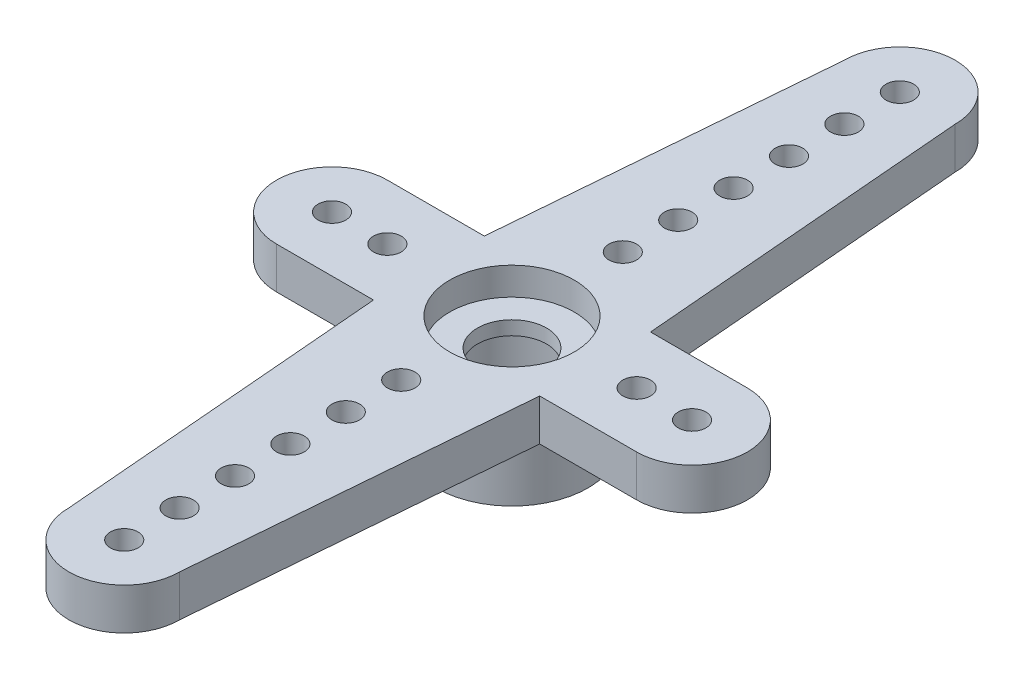
from build123d import *

# Parameters (mm, degrees)
ESQUISSE1_R             = 2.75
ESQUISSE1_R_2           = 2.25
BOSS_EXTRU_1_DEPTH      = 2.5
BOSS_EXTRU_2_DEPTH      = 1.5
ESQUISSE4_R             = 2.25
ENL_V_MAT_EXTRU_1_DEPTH = 1
ENL_V_MAT_EXTRU_2_REACH = 5
ESQUISSE5_R             = 1.25
ESQUISSE6_R             = 0.5
ENL_V_MAT_EXTRU_3_DEPTH = 5


with BuildPart() as part:
    # Esquisse1 → Boss.-Extru.1 (new body)
    with BuildSketch(Plane(origin=(0, 0, 0), x_dir=(1, 0, 0), z_dir=(0, 1, 0))):
        Circle(ESQUISSE1_R)
        Circle(ESQUISSE1_R_2, mode=Mode.SUBTRACT)
    extrude(amount=BOSS_EXTRU_1_DEPTH)

    # Esquisse3 → Boss.-Extru.2 (add)
    with BuildSketch(Plane(origin=(0, 2.5, 0), x_dir=(1, 0, 0), z_dir=(0, 1, 0))):
        with BuildLine():
            Line((-6.5, 2), (-3, 2))
            Line((-3, 2), (-2, 14))
            ThreePointArc((-2, 14), (0, 16), (2, 14))
            Line((2, 14), (3, 2))
            Line((3, 2), (6.5, 2))
            ThreePointArc((6.5, 2), (8.5, 0), (6.5, -2))
            Line((6.5, -2), (3, -2))
            Line((3, -2), (2, -14))
            ThreePointArc((2, -14), (0, -16), (-2, -14))
            Line((-2, -14), (-3, -2))
            Line((-3, -2), (-6.5, -2))
            ThreePointArc((-6.5, -2), (-8.5, 0), (-6.5, 2))
        make_face()
    extrude(amount=BOSS_EXTRU_2_DEPTH)

    # Esquisse4 → Enlèv. mat.-Extru.1 (cut)
    with BuildSketch(Plane(origin=(0, 4, 0), x_dir=(1, 0, 0), z_dir=(0, 1, 0))):
        Circle(ESQUISSE4_R)
    extrude(amount=-ENL_V_MAT_EXTRU_1_DEPTH, mode=Mode.SUBTRACT)

    # Esquisse5 → Enlèv. mat.-Extru.2 (cut, up to next)
    with BuildSketch(Plane(origin=(0, 3, 0), x_dir=(1, 0, 0), z_dir=(0, 1, 0)), mode=Mode.PRIVATE) as enl_v_mat_extru_2_sk1:
        Circle(ESQUISSE5_R)
    enl_v_mat_extru_2_tool1 = extrude(enl_v_mat_extru_2_sk1.sketch, amount=-ENL_V_MAT_EXTRU_2_REACH, mode=Mode.PRIVATE) & part.part
    add(enl_v_mat_extru_2_tool1.solids().sort_by_distance((0, 3, 0))[0], mode=Mode.SUBTRACT)

    # Esquisse6 → Enlèv. mat.-Extru.3 (cut, through all)
    with BuildSketch(Plane(origin=(0, 4, 0), x_dir=(1, 0, 0), z_dir=(0, 1, 0))):
        with Locations((4.5, 0)):
            Circle(ESQUISSE6_R)
        with Locations((6.5, 0)):
            Circle(ESQUISSE6_R)
        with Locations((-4.5, 0)):
            Circle(ESQUISSE6_R)
        with Locations((-6.5, 0)):
            Circle(ESQUISSE6_R)
        with Locations((0, 14)):
            Circle(ESQUISSE6_R)
        with Locations((0, 12)):
            Circle(ESQUISSE6_R)
        with Locations((0, 10)):
            Circle(ESQUISSE6_R)
        with Locations((0, 8)):
            Circle(ESQUISSE6_R)
        with Locations((0, 6)):
            Circle(ESQUISSE6_R)
        with Locations((0, 4)):
            Circle(ESQUISSE6_R)
        with Locations((0, -4)):
            Circle(ESQUISSE6_R)
        with Locations((0, -6)):
            Circle(ESQUISSE6_R)
        with Locations((0, -8)):
            Circle(ESQUISSE6_R)
        with Locations((0, -10)):
            Circle(ESQUISSE6_R)
        with Locations((0, -12)):
            Circle(ESQUISSE6_R)
        with Locations((0, -14)):
            Circle(ESQUISSE6_R)
    extrude(amount=-ENL_V_MAT_EXTRU_3_DEPTH, mode=Mode.SUBTRACT)


solid = part.part
